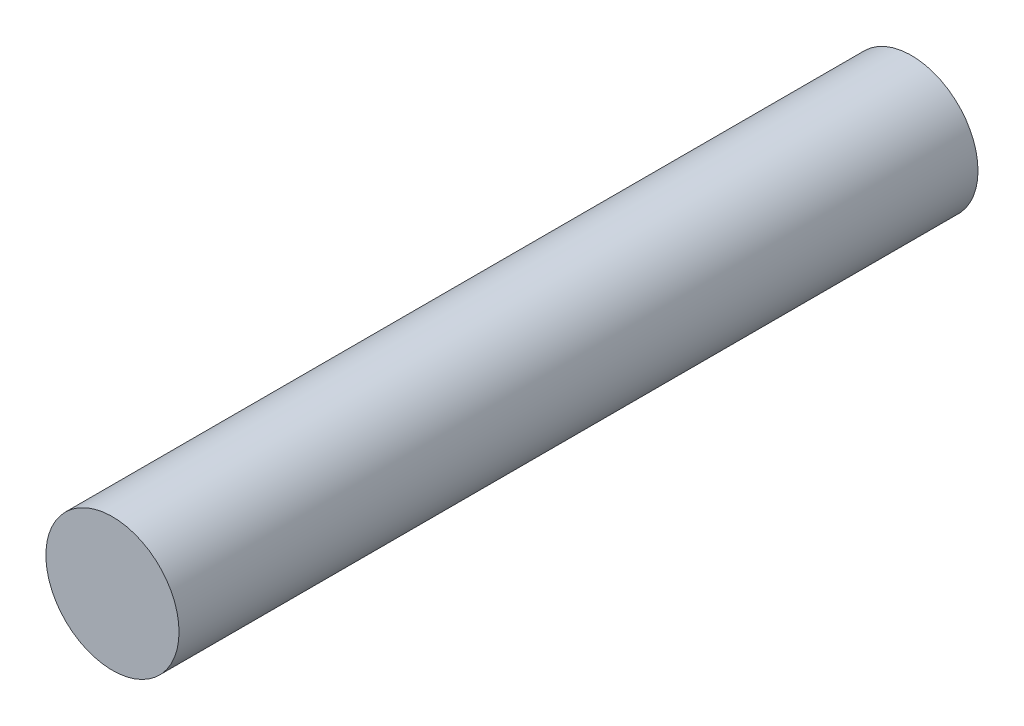
from build123d import *

# Parameters (mm, degrees)
SKETCH1_R           = 4.7625
BOSS_EXTRUDE1_DEPTH = 57.15


with BuildPart() as part:
    # Sketch1 → Boss-Extrude1 (new body)
    with BuildSketch(Plane.XY):
        Circle(SKETCH1_R)
    extrude(amount=-BOSS_EXTRUDE1_DEPTH)


solid = part.part
